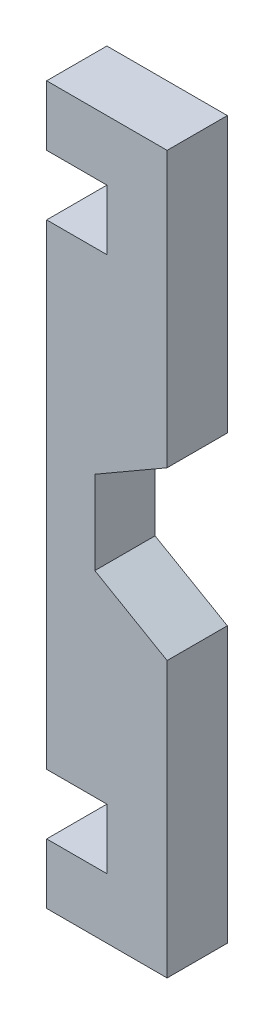
from build123d import *

# Parameters (mm, degrees)
BOSS_EXTRUDE1_DEPTH = 5


with BuildPart() as part:
    # Sketch1 → Boss-Extrude1 (new body)
    with BuildSketch(Plane.XY):
        Polygon((0, -12.82179677), (0, 0), (0, 10), (-5, 10), (-10, 10), (-10, 5), (-5, 5), (-5, 0), (-10, 0), (-10, -39.5), (-5, -39.5), (-5, -44.5), (-10, -44.5), (-10, -49.5), (-5, -49.5), (0, -49.5), (0, -39.5), (0, -26.67820323), (-6, -23.214101615), (-6, -16.285898385), align=None)
    extrude(amount=BOSS_EXTRUDE1_DEPTH)


solid = part.part
